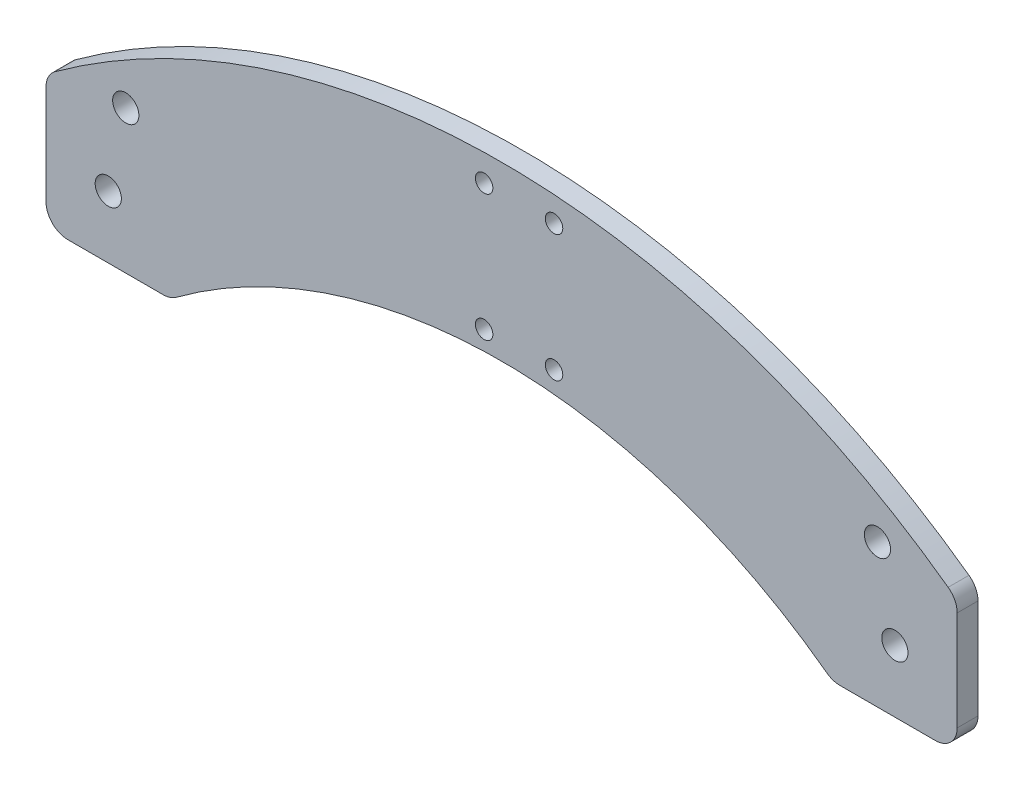
from build123d import *

# Parameters (mm, degrees)
SKETCH1_R           = 2
SKETCH1_R_2         = 3
BOSS_EXTRUDE1_DEPTH = 4.7625


with BuildPart() as part:
    # Sketch1 → Boss-Extrude1 (new body)
    with BuildSketch(Plane.XY):
        with BuildLine():
            Line((-14.25, -9.25), (-14.25, 13.536101268))
            ThreePointArc((-14.25, 13.536101268), (-13.704321085, 15.807449693), (-12.186390533, 17.583027341))
            ThreePointArc((-12.186390533, 17.583027341), (90, 50.75), (192.186390533, 17.583027341))
            ThreePointArc((192.186390533, 17.583027341), (193.704321085, 15.807449693), (194.25, 13.536101268))
            Line((194.25, 13.536101268), (194.25, -9.25))
            ThreePointArc((194.25, -9.25), (192.785533906, -12.785533906), (189.25, -14.25))
            Line((189.25, -14.25), (167.419194615, -14.25))
            ThreePointArc((167.419194615, -14.25), (165.851279553, -13.997803951), (164.441533284, -13.266656943))
            ThreePointArc((164.441533284, -13.266656943), (90, 11.316919489), (15.558466716, -13.266656943))
            ThreePointArc((15.558466716, -13.266656943), (14.148720447, -13.997803951), (12.580805385, -14.25))
            Line((12.580805385, -14.25), (-9.25, -14.25))
            ThreePointArc((-9.25, -14.25), (-12.785533906, -12.785533906), (-14.25, -9.25))
        make_face()
        with Locations((86, 44.6)):
            Circle(SKETCH1_R, mode=Mode.SUBTRACT)
        with Locations((86, 15.6)):
            Circle(SKETCH1_R, mode=Mode.SUBTRACT)
        with Locations((102, 44.6)):
            Circle(SKETCH1_R, mode=Mode.SUBTRACT)
        with Locations((102, 15.6)):
            Circle(SKETCH1_R, mode=Mode.SUBTRACT)
        with Locations((180, 0)):
            Circle(SKETCH1_R_2, mode=Mode.SUBTRACT)
        Circle(SKETCH1_R_2, mode=Mode.SUBTRACT)
        with Locations((4, 18.5)):
            Circle(SKETCH1_R_2, mode=Mode.SUBTRACT)
        with Locations((176, 18.5)):
            Circle(SKETCH1_R_2, mode=Mode.SUBTRACT)
    extrude(amount=BOSS_EXTRUDE1_DEPTH)


solid = part.part
